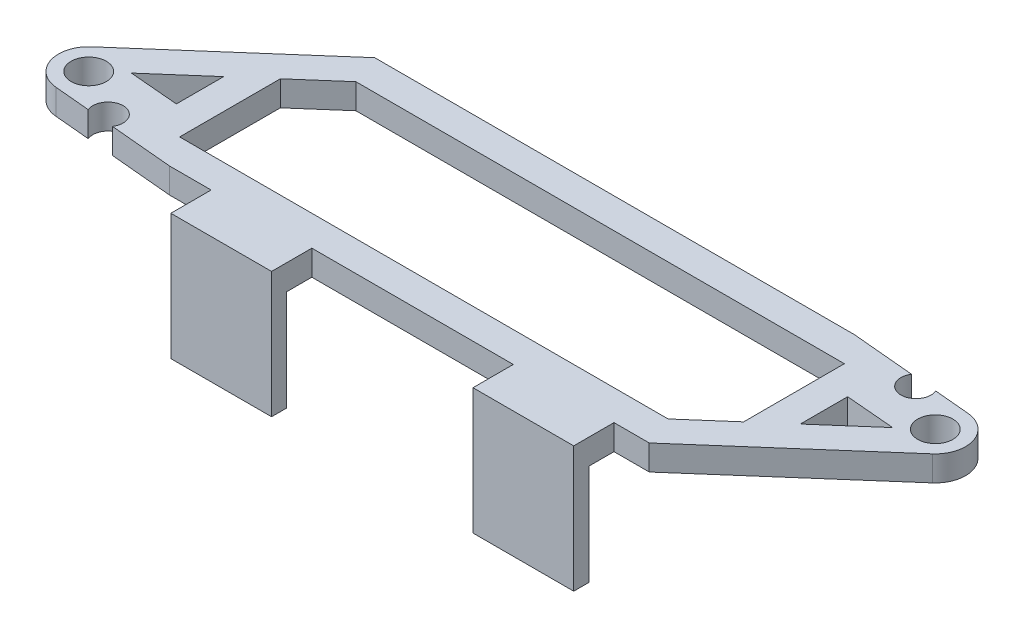
from build123d import *

# Parameters (mm, degrees)
SKETCH1_R           = 3.5
BOSS_EXTRUDE1_DEPTH = 5
SKETCH2_W           = 20
SKETCH2_H           = 3
BOSS_EXTRUDE2_DEPTH = 20


with BuildPart() as part:
    # Sketch1 → Boss-Extrude1 (new body)
    with BuildSketch(Plane(origin=(0, 0, 0), x_dir=(1, 0, 0), z_dir=(0, 1, 0))):
        with BuildLine():
            Line((-46.754410697, 33), (48.5, 33))
            Line((48.5, 33), (60.984651798, 31.862682764))
            ThreePointArc((60.984651798, 31.862682764), (63.227835275, 27.240115524), (66.269368613, 31.381259683))
            Line((66.269368613, 31.381259683), (73.34328665, 30.736845322))
            ThreePointArc((73.34328665, 30.736845322), (78.505606793, 26.614733634), (76.749984847, 20.246127381))
            Line((76.749984847, 20.246127381), (46.754410697, -6))
            Line((46.754410697, -6), (39.754410697, -6))
            Line((39.754410697, -6), (39.754410697, -14))
            Line((39.754410697, -14), (19.754410697, -14))
            Line((19.754410697, -14), (19.754410697, -6))
            Line((19.754410697, -6), (-20.245589303, -6))
            Line((-20.245589303, -6), (-20.245589303, -14))
            Line((-20.245589303, -14), (-40.245589303, -14))
            Line((-40.245589303, -14), (-40.245589303, -6))
            Line((-40.245589303, -6), (-48.5, -6))
            Line((-48.5, -6), (-60.984651798, -4.862682764))
            ThreePointArc((-60.984651798, -4.862682764), (-63.227835275, -0.240115524), (-66.269368613, -4.381259683))
            Line((-66.269368613, -4.381259683), (-73.34328665, -3.736845322))
            ThreePointArc((-73.34328665, -3.736845322), (-78.505606793, 0.385266366), (-76.749984847, 6.753872619))
            Line((-76.749984847, 6.753872619), (-46.754410697, 33))
        make_face()
        with Locations((72.798957199, 24.76158755)):
            Circle(SKETCH1_R, mode=Mode.SUBTRACT)
        with Locations((-72.798957199, 2.23841245)):
            Circle(SKETCH1_R, mode=Mode.SUBTRACT)
        Polygon((-44.5, 27), (52.5, 27), (52.5, 7), (44.5, 0), (-52.5, 0), (-52.5, 20), align=None, mode=Mode.SUBTRACT)
        Polygon((58.5, 21.65), (58.5, 12.25), (68.283497031, 20.810559902), align=None, mode=Mode.SUBTRACT)
        Polygon((-58.5, 14.75), (-68.283497031, 6.189440098), (-58.5, 5.35), align=None, mode=Mode.SUBTRACT)
    extrude(amount=BOSS_EXTRUDE1_DEPTH)

    # Sketch2 → Boss-Extrude2 (add)
    with BuildSketch(Plane.XZ):
        with Locations((-30.245589303, 12.5)):
            Rectangle(SKETCH2_W, SKETCH2_H)
        with Locations((29.754410697, 12.5)):
            Rectangle(SKETCH2_W, SKETCH2_H)
    extrude(amount=BOSS_EXTRUDE2_DEPTH)


solid = part.part
